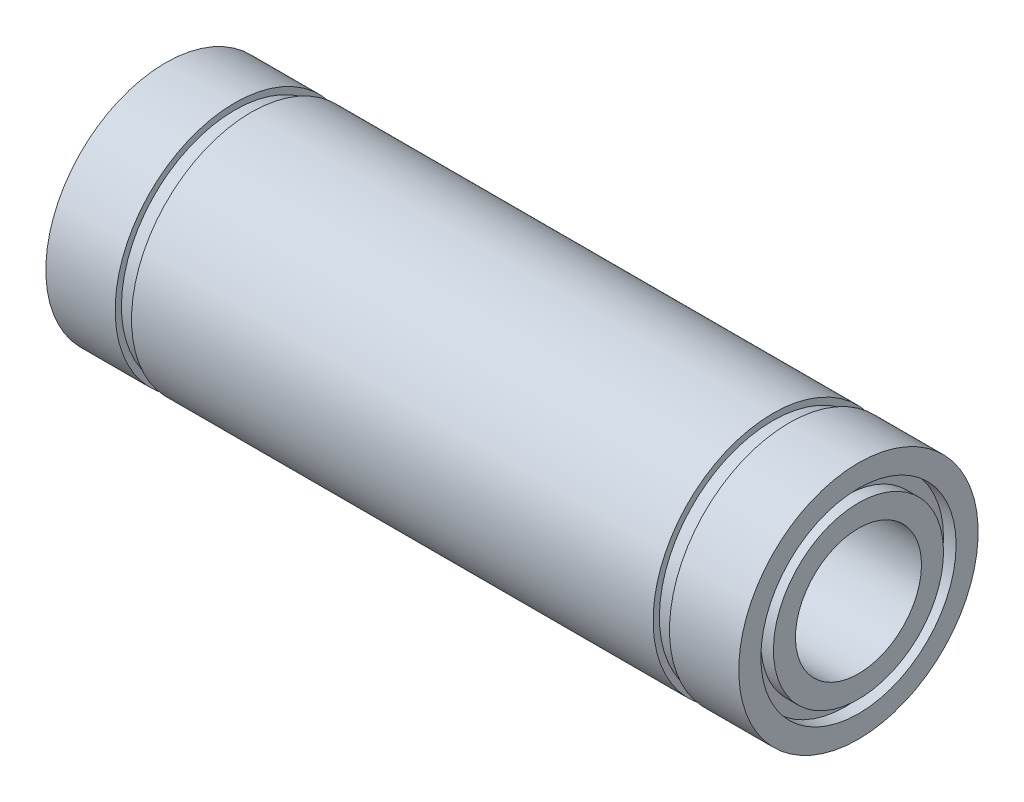
from build123d import *


with BuildPart() as part:
    # Esboço1 → Revolução1 (revolve)
    with BuildSketch(Plane.XY):
        Polygon((-27.5, 9.5), (-22, 9.5), (-22, 9), (-20.7, 9), (-20.7, 9.5), (20.7, 9.5), (20.7, 9), (22, 9), (22, 9.5), (27.5, 9.5), (27.5, 7.75), (26.5, 7.75), (26.5, 6.75), (27.5, 6.75), (27.5, 5), (-27.5, 5), (-27.5, 6.75), (-26.5, 6.75), (-26.5, 7.75), (-27.5, 7.75), align=None)
    revolve(axis=Axis((0, 0, 0), (-1, 0, 0)))


solid = part.part
